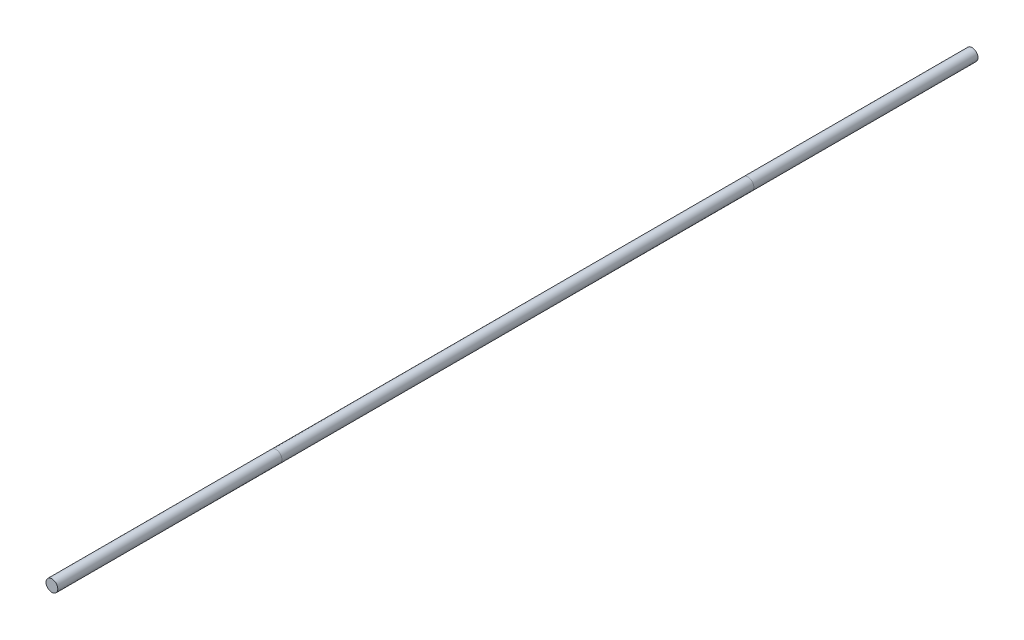
from build123d import *

# Parameters (mm, degrees)
SKETCH1_R          = 3.175
BASE_EXTRUDE_DEPTH = 247.65


with BuildPart() as part:
    # Sketch1 → Base-Extrude (new body, symmetric)
    with BuildSketch(Plane.XY):
        Circle(SKETCH1_R)
    extrude(amount=BASE_EXTRUDE_DEPTH, both=True)


solid = part.part
